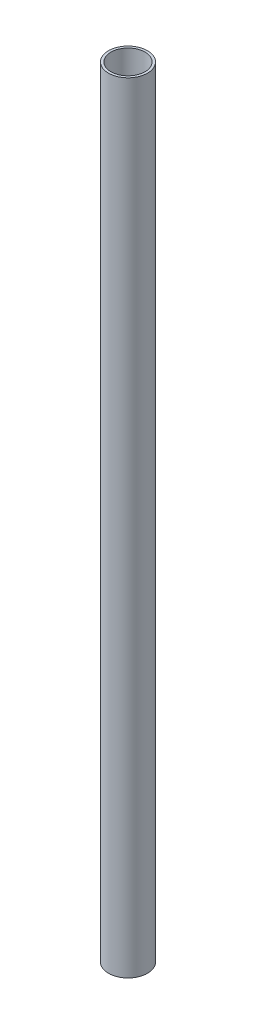
from build123d import *

# Parameters (mm, degrees)
SKETCH1_R           = 50.8
SKETCH1_R_2         = 44.45
BOSS_EXTRUDE1_DEPTH = 2032


with BuildPart() as part:
    # Sketch1 → Boss-Extrude1 (new body)
    with BuildSketch(Plane(origin=(0, 0, 0), x_dir=(1, 0, 0), z_dir=(0, 1, 0))):
        Circle(SKETCH1_R)
        Circle(SKETCH1_R_2, mode=Mode.SUBTRACT)
    extrude(amount=BOSS_EXTRUDE1_DEPTH)


solid = part.part
